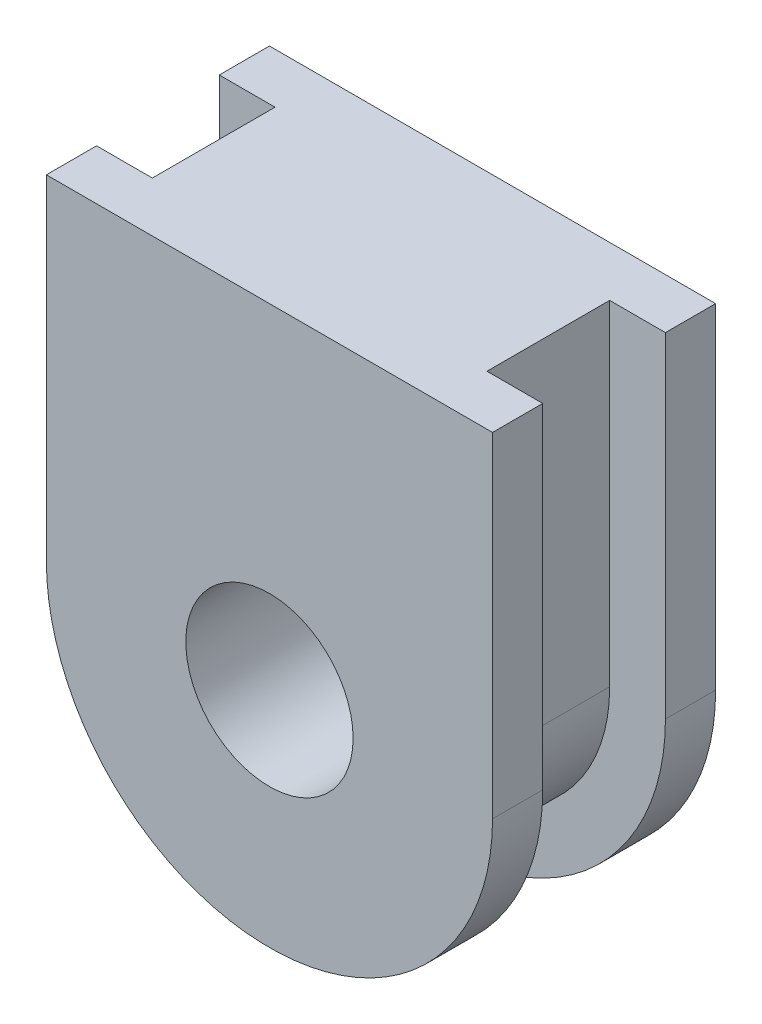
from build123d import *

# Parameters (mm, degrees)
SKIZZE1_R                       = 1.5
AUFSATZ_LINEAR_AUSTRAGEN1_DEPTH = 2
SKIZZE2_OUTSIDE_W               = 12.684
SKIZZE2_OUTSIDE_H               = 14.684
SCHNITT_LINEAR_AUSTRAGEN1_DEPTH = 1.1


with BuildPart() as part:
    # Skizze1 → Aufsatz-Linear austragen1 (new body, symmetric)
    with BuildSketch(Plane.XY):
        with BuildLine():
            Line((-4, 0), (-4, 6))
            Line((-4, 6), (4, 6))
            Line((4, 6), (4, 0))
            ThreePointArc((4, 0), (0, -4), (-4, 0))
        make_face()
        Circle(SKIZZE1_R, mode=Mode.SUBTRACT)
    extrude(amount=AUFSATZ_LINEAR_AUSTRAGEN1_DEPTH, both=True)

    # Skizze2 outside → Schnitt-Linear austragen1 (cut, symmetric)
    with BuildSketch(Plane.XY):
        with Locations((0, 1)):
            Rectangle(SKIZZE2_OUTSIDE_W, SKIZZE2_OUTSIDE_H)
        with BuildLine():
            Line((-3, 6), (3, 6))
            Line((3, 6), (3, 0))
            ThreePointArc((3, 0), (0, -3), (-3, 0))
            Line((-3, 0), (-3, 6))
        make_face(mode=Mode.SUBTRACT)
    extrude(amount=SCHNITT_LINEAR_AUSTRAGEN1_DEPTH, both=True, mode=Mode.SUBTRACT)


solid = part.part
